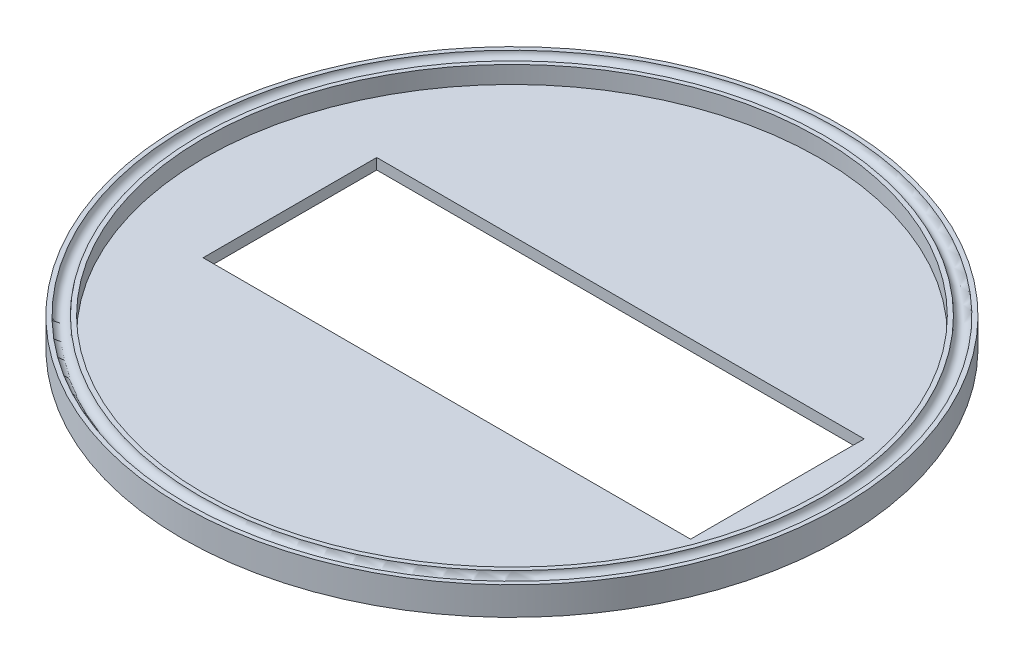
from build123d import *

# Parameters (mm, degrees)
SKETCH1_R            = 75.925
BOSS_EXTRUDE1_DEPTH  = 2.5
SKETCH2_W            = 112.3
SKETCH2_H            = 40
CUT_EXTRUDE1_DEPTH   = 3.5
SKETCH10_R           = 75.925
SKETCH10_R_2         = 70.925
BOSS_EXTRUDE2_DEPTH  = 4
CUT_SWEEP3_PROFILE_R = 1.5


with BuildPart() as part:
    # Sketch1 → Boss-Extrude1 (new body)
    with BuildSketch(Plane(origin=(0, 0, 0), x_dir=(1, 0, 0), z_dir=(0, 1, 0))):
        Circle(SKETCH1_R)
    extrude(amount=BOSS_EXTRUDE1_DEPTH)

    # Sketch2 → Cut-Extrude1 (cut, through all)
    with BuildSketch(Plane(origin=(0, 2.5, 0), x_dir=(1, 0, 0), z_dir=(0, 1, 0))):
        with Locations((5, 0)):
            Rectangle(SKETCH2_W, SKETCH2_H)
    extrude(amount=-CUT_EXTRUDE1_DEPTH, mode=Mode.SUBTRACT)

    # Sketch10 → Boss-Extrude2 (add)
    with BuildSketch(Plane(origin=(0, 2.5, 0), x_dir=(1, 0, 0), z_dir=(0, 1, 0))):
        Circle(SKETCH10_R)
        Circle(SKETCH10_R_2, mode=Mode.SUBTRACT)
    extrude(amount=BOSS_EXTRUDE2_DEPTH)

    # Cut-Sweep3: sweep along a path in Sketch12
    with BuildLine(Plane(origin=(0, 6.5, 0), x_dir=(1, 0, 0), z_dir=(0, 1, 0))) as cut_sweep3_path:
        CenterArc((0, 0), 73.425, 0, 360)
    # Cut-Sweep3 profile (on start of the path) → Cut-Sweep3 (sweep, cut)
    with BuildSketch(Plane(origin=(73.425, 6.5, 0), x_dir=(-1, 0, 0), z_dir=(0, 0, -1))):
        Circle(CUT_SWEEP3_PROFILE_R)
    sweep(path=cut_sweep3_path.line, mode=Mode.SUBTRACT)


solid = part.part
